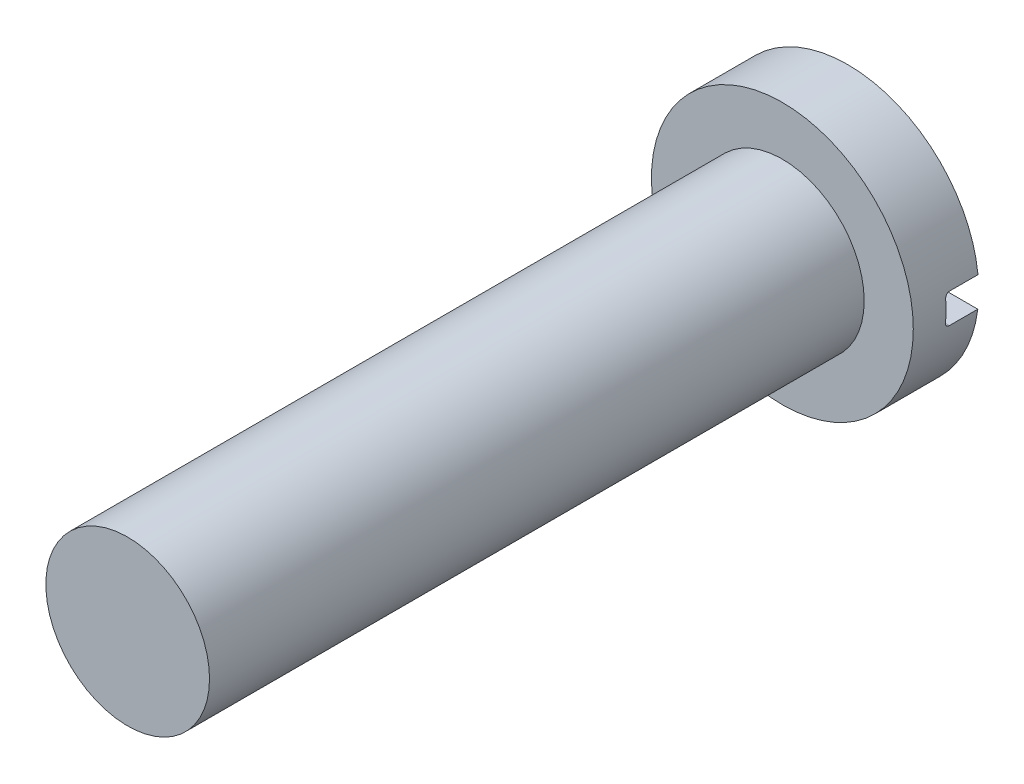
from build123d import *

# Parameters (mm, degrees)
SKETCH1_R           = 3
BOSS_EXTRUDE1_DEPTH = 1.5
SKETCH2_R           = 1.875
BOSS_EXTRUDE2_DEPTH = 15
CUT_EXTRUDE1_DEPTH  = 0.75
FILLET2_R           = 0.1


with BuildPart() as part:
    # Sketch1 → Boss-Extrude1 (new body)
    with BuildSketch(Plane.XY):
        Circle(SKETCH1_R)
    extrude(amount=BOSS_EXTRUDE1_DEPTH)

    # Sketch2 → Boss-Extrude2 (add)
    with BuildSketch(Plane.XY.offset(1.5)):
        Circle(SKETCH2_R)
    extrude(amount=BOSS_EXTRUDE2_DEPTH)

    # Sketch3 → Cut-Extrude1 (cut)
    with BuildSketch(Plane(origin=(0, 0, 0), x_dir=(-1, 0, 0), z_dir=(0, 0, -1))):
        with BuildLine():
            Line((2.977836652, 0.322793516), (-2.982583502, 0.322793516))
            ThreePointArc((-2.982583502, 0.322793516), (-3, 0), (-2.982583502, -0.322793516))
            ThreePointArc((-2.982583502, -0.322793516), (-2.980281261, -0.343400064), (-2.977836652, -0.363990208))
            Line((-2.977836652, -0.363990208), (2.977836652, -0.363990208))
            ThreePointArc((2.977836652, -0.363990208), (2.994454037, -0.182332173), (3, 0))
            ThreePointArc((3, 0), (2.995642711, 0.161631516), (2.982583502, 0.322793516))
            Line((2.982583502, 0.322793516), (2.977836652, 0.322793516))
        make_face()
    extrude(amount=-CUT_EXTRUDE1_DEPTH, mode=Mode.SUBTRACT)

    # Fillet2
    fillet2_edges = [part.edges().sort_by_distance(p)[0] for p in [
        (0, -0.363990208, 0.75),
        (0, 0.322793516, 0.75),
    ]]
    fillet(fillet2_edges, radius=FILLET2_R)


solid = part.part
